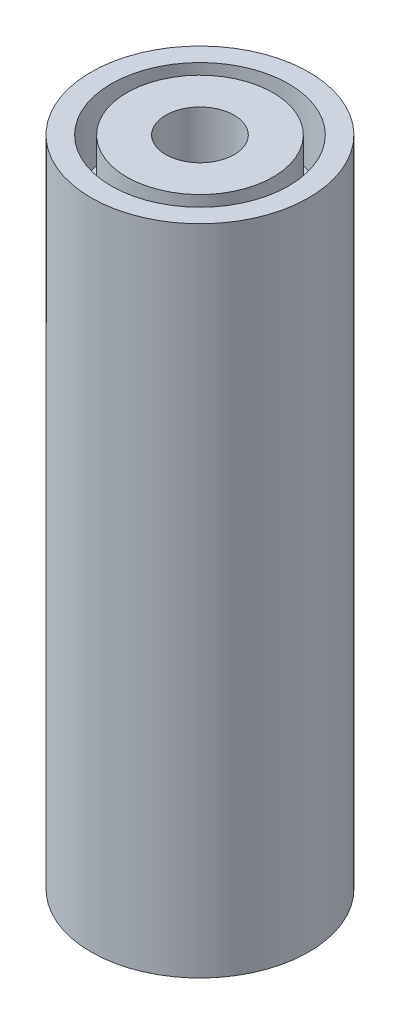
from build123d import *

# Parameters (mm, degrees)
ESQUISSE1_R             = 3.5
ESQUISSE1_R_2           = 1.1
BOSS_EXTRU_2_DEPTH      = 21
ESQUISSE2_R             = 2.85
ESQUISSE2_R_2           = 2.35
ENL_V_MAT_EXTRU_1_DEPTH = 2


with BuildPart() as part:
    # Esquisse1 → Boss.-Extru.2 (new body)
    with BuildSketch(Plane(origin=(0, 0, 0), x_dir=(1, 0, 0), z_dir=(0, 1, 0))):
        Circle(ESQUISSE1_R)
        Circle(ESQUISSE1_R_2, mode=Mode.SUBTRACT)
    extrude(amount=BOSS_EXTRU_2_DEPTH)

    # Esquisse2 → Enlèv. mat.-Extru.1 (cut)
    with BuildSketch(Plane(origin=(0, 21, 0), x_dir=(1, 0, 0), z_dir=(0, 1, 0))):
        Circle(ESQUISSE2_R)
        Circle(ESQUISSE2_R_2, mode=Mode.SUBTRACT)
    extrude(amount=-ENL_V_MAT_EXTRU_1_DEPTH, mode=Mode.SUBTRACT)


solid = part.part
